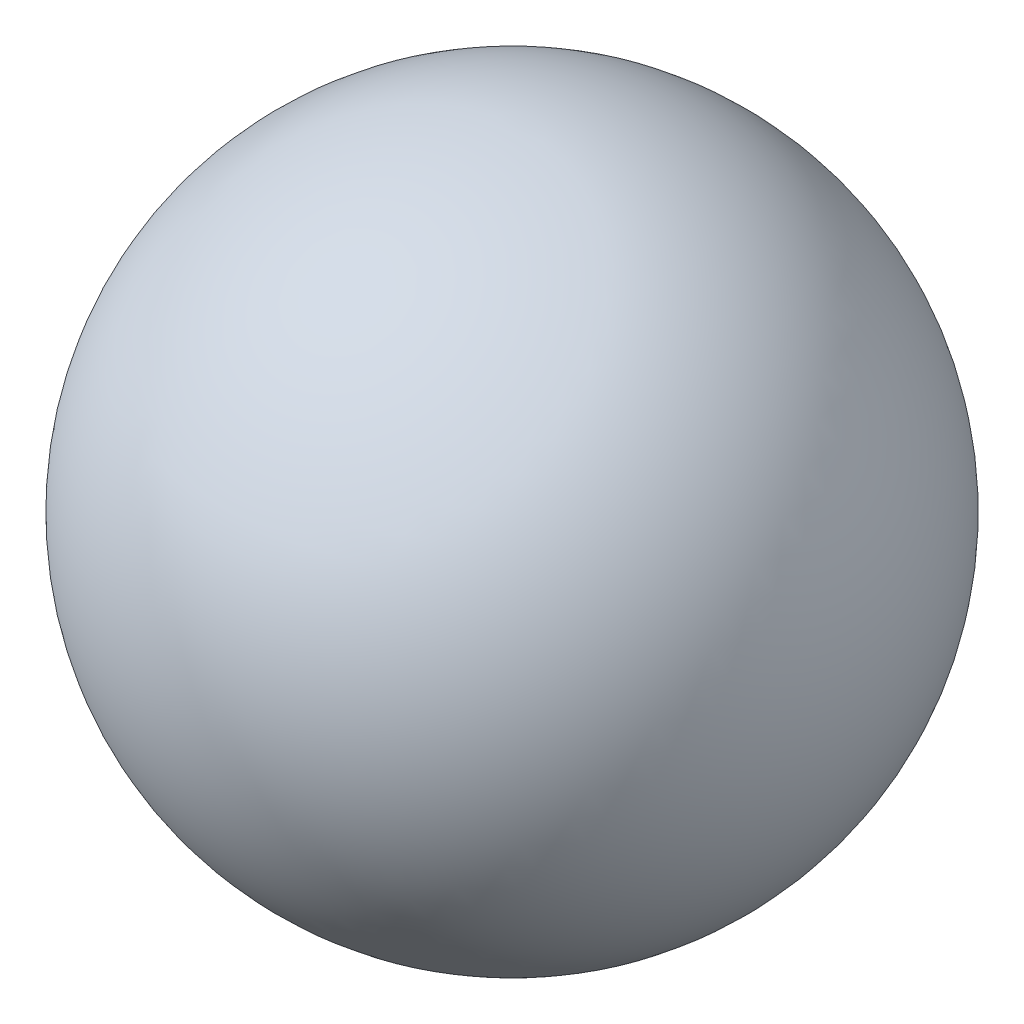
from build123d import *


with BuildPart() as part:
    # Sketch1 → Revolve1 (revolve)
    with BuildSketch(Plane.XY):
        with BuildLine():
            Line((0, 1.5), (0, -1.5))
            ThreePointArc((0, -1.5), (1.5, 0), (0, 1.5))
        make_face()
    revolve(axis=Axis((0, 1.5, 0), (0, -1, 0)))


solid = part.part
